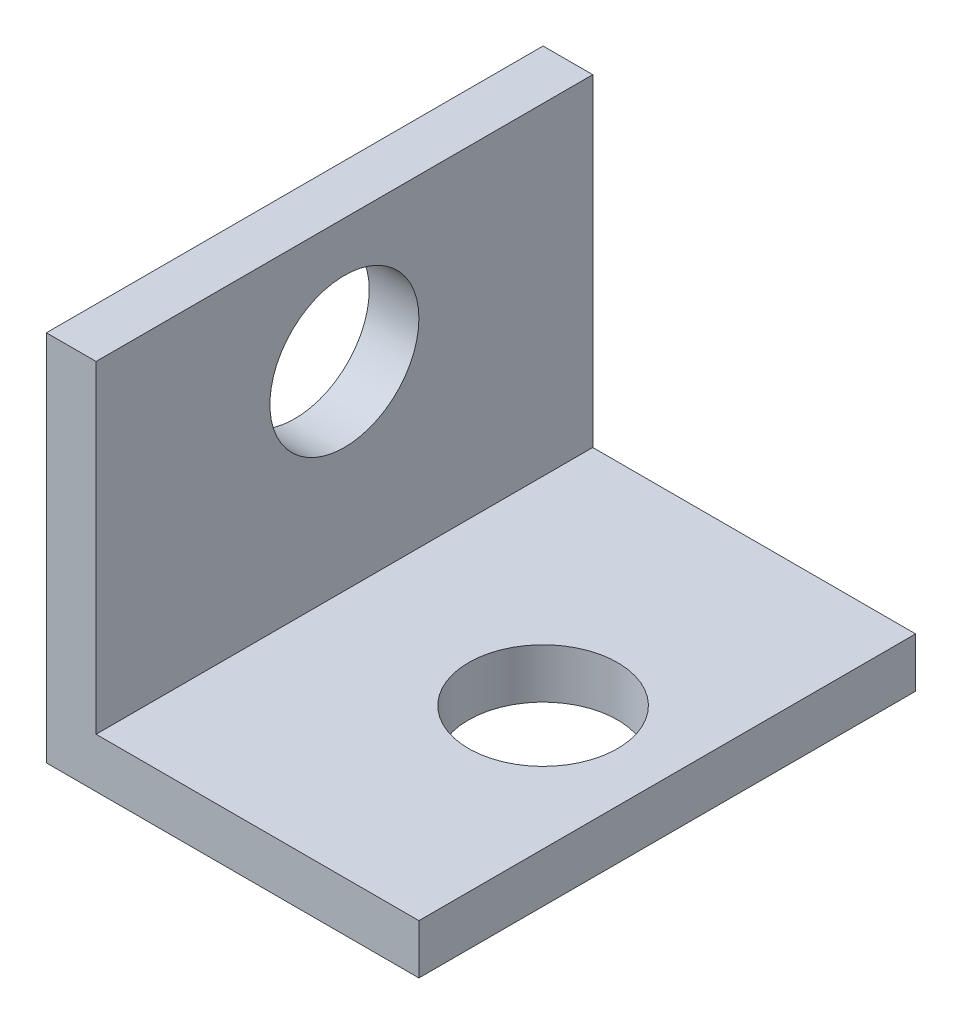
from build123d import *

# Parameters (mm, degrees)
BOSS_EXTRUDE1_DEPTH = 20
CUT_EXTRUDE1_REACH  = 4
SKETCH2_R           = 3
SKETCH3_R           = 3
CUT_EXTRUDE2_DEPTH  = 20


with BuildPart() as part:
    # Sketch1 → Boss-Extrude1 (new body)
    with BuildSketch(Plane.XY):
        Polygon((0, 0), (15, 0), (15, 2), (2, 2), (2, 15), (0, 15), align=None)
    extrude(amount=BOSS_EXTRUDE1_DEPTH)

    # Sketch2 → Cut-Extrude1 (cut, up to next)
    with BuildSketch(Plane(origin=(0, 2, 0), x_dir=(1, 0, 0), z_dir=(0, 1, 0)), mode=Mode.PRIVATE) as cut_extrude1_sk1:
        with Locations((10, -10)):
            Circle(SKETCH2_R)
    cut_extrude1_tool1 = extrude(cut_extrude1_sk1.sketch, amount=-CUT_EXTRUDE1_REACH, mode=Mode.PRIVATE) & part.part
    add(cut_extrude1_tool1.solids().sort_by_distance((10, 2, 10))[0], mode=Mode.SUBTRACT)

    # Sketch3 → Cut-Extrude2 (cut)
    with BuildSketch(Plane(origin=(2, 0, 0), x_dir=(0, 0, -1), z_dir=(1, 0, 0))):
        with Locations((-10, 10)):
            Circle(SKETCH3_R)
    extrude(amount=-CUT_EXTRUDE2_DEPTH, mode=Mode.SUBTRACT)


solid = part.part
